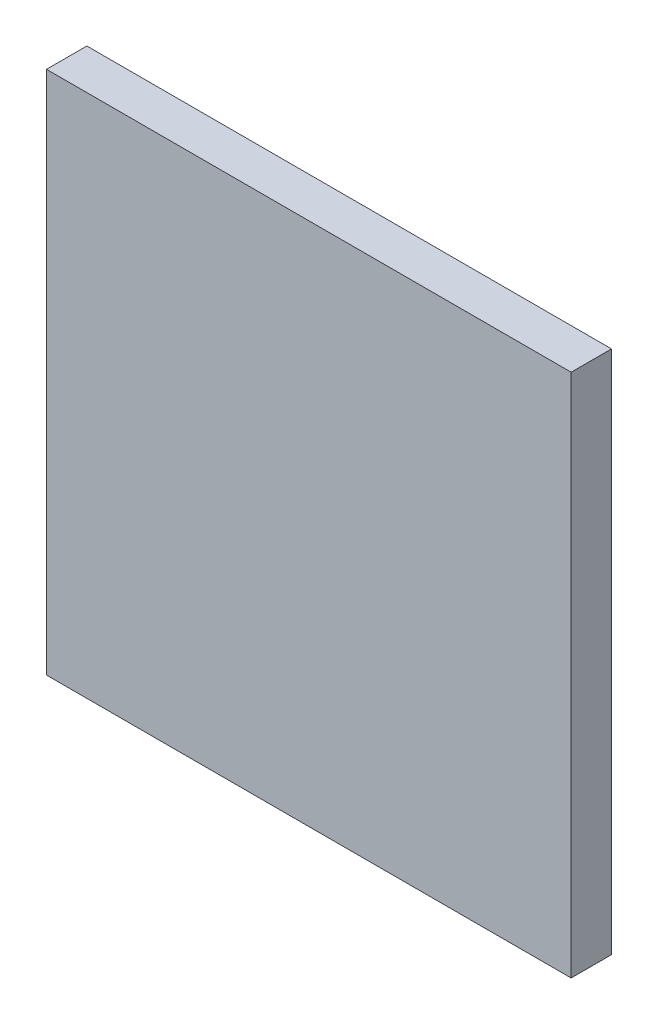
from build123d import *

# Parameters (mm, degrees)
SKETCH1_W           = 130
SKETCH1_H           = 130
BOSS_EXTRUDE1_DEPTH = 10


with BuildPart() as part:
    # Sketch1 → Boss-Extrude1 (new body)
    with BuildSketch(Plane.XY):
        Rectangle(SKETCH1_W, SKETCH1_H)
    extrude(amount=BOSS_EXTRUDE1_DEPTH)


solid = part.part
